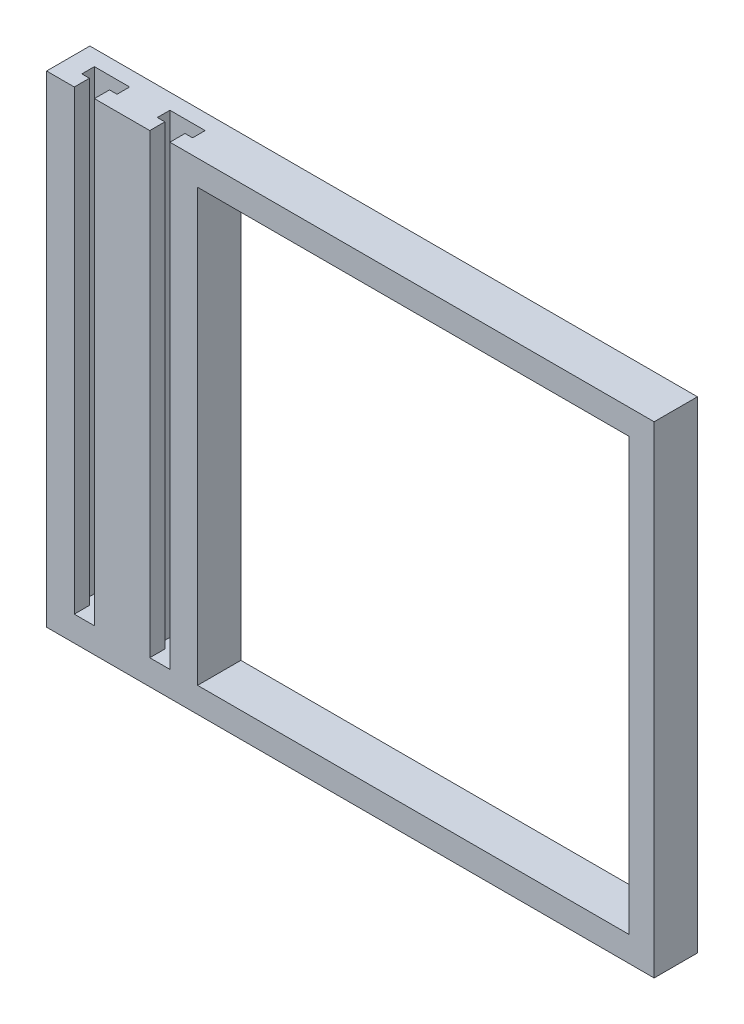
from build123d import *

# Parameters (mm, degrees)
SKETCH_1_W          = 95.7
SKETCH_1_H          = 95.7
SKETCH_1_W_2        = 85.7
SKETCH_1_H_2        = 85.7
EXTRUDE_1_DEPTH     = 8.6
SKETCH_2_W          = 8.6
SKETCH_2_H          = 95.7
EXTRUDE_2_DEPTH     = 25
CUT_EXTRUDE_2_DEPTH = 90.7


with BuildPart() as part:
    # 草图1 → 凸台-拉伸1 (new body)
    with BuildSketch(Plane.XY):
        Rectangle(SKETCH_1_W, SKETCH_1_H)
        Rectangle(SKETCH_1_W_2, SKETCH_1_H_2, mode=Mode.SUBTRACT)
    extrude(amount=EXTRUDE_1_DEPTH)

    # 草图2 → 凸台-拉伸2 (add)
    with BuildSketch(Plane.ZY.offset(47.85)):
        with Locations((4.3, 0)):
            Rectangle(SKETCH_2_W, SKETCH_2_H)
    extrude(amount=EXTRUDE_2_DEPTH)

    # 草图5 → 切除-拉伸2 (cut)
    with BuildSketch(Plane(origin=(0, 47.85, 0), x_dir=(1, 0, 0), z_dir=(0, 1, 0))):
        Polygon((-67.35, -8.6), (-63.35, -8.6), (-63.35, -5.6), (-61.85, -5.6), (-61.85, -3.1), (-68.85, -3.1), (-68.85, -5.6), (-67.35, -5.6), align=None)
        Polygon((-53.85, -5.6), (-53.85, -3.1), (-46.85, -3.1), (-46.85, -5.6), (-48.35, -5.6), (-48.35, -8.6), (-52.35, -8.6), (-52.35, -5.6), align=None)
    extrude(amount=-CUT_EXTRUDE_2_DEPTH, mode=Mode.SUBTRACT)


solid = part.part
